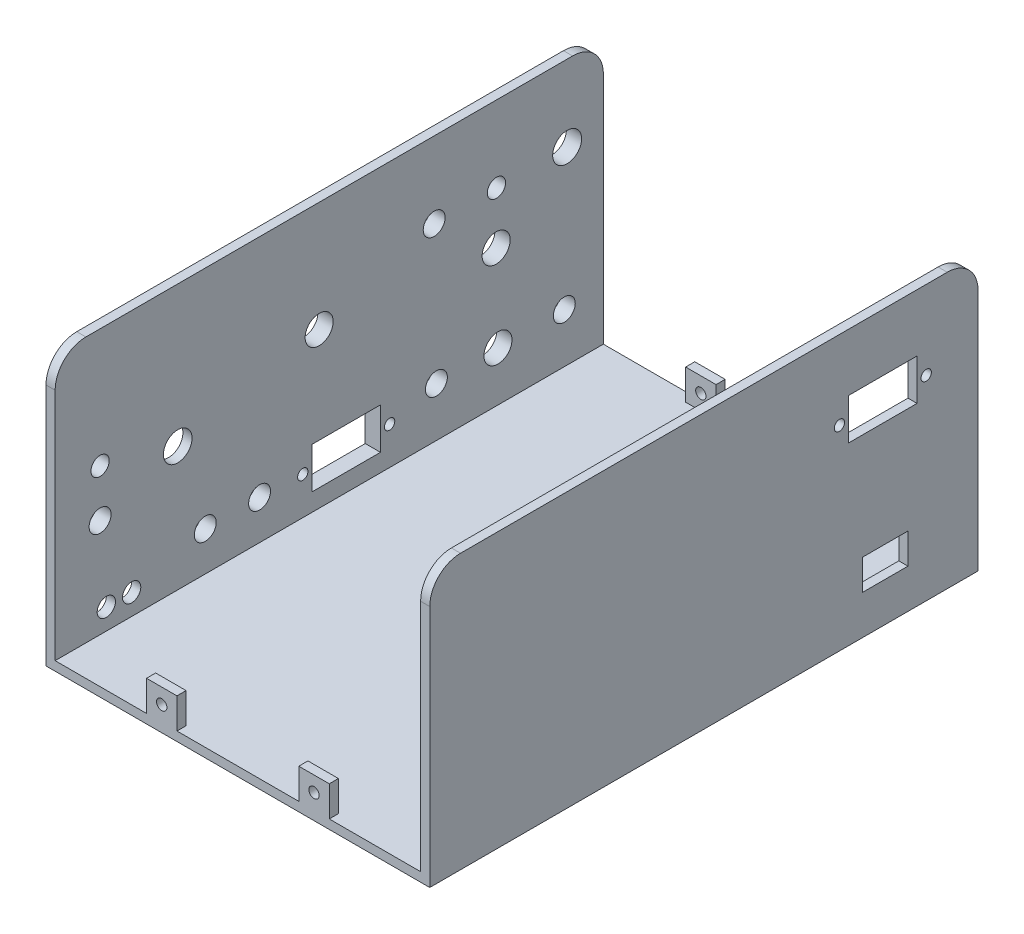
from build123d import *

# Parameters (mm, degrees)
SKETCH1_W           = 126
SKETCH1_H           = 90
BOSS_EXTRUDE1_DEPTH = 3
BOSS_EXTRUDE2_DEPTH = 177
SKETCH3_W           = 126
SKETCH3_H           = 90
BOSS_EXTRUDE3_DEPTH = 3
FILLET1_R           = 10
SKETCH5_R           = 3
CUT_EXTRUDE1_DEPTH  = 5
SKETCH6_W           = 22.5
SKETCH6_H           = 13.5
SKETCH6_W_2         = 15
SKETCH6_H_2         = 10
CUT_EXTRUDE2_DEPTH  = 3
SKETCH7_W           = 180
SKETCH7_H           = 180
BOSS_EXTRUDE5_DEPTH = 3
SKETCH8_OUTSIDE_W   = 236
SKETCH8_OUTSIDE_H   = 146
CUT_EXTRUDE3_DEPTH  = 181
SKETCH9_W           = 120
SKETCH9_H           = 87
CUT_EXTRUDE4_DEPTH  = 181
SKETCH11_W          = 10
SKETCH11_H          = 3
BOSS_EXTRUDE6_DEPTH = 10
SKETCH12_R          = 1.7
CUT_EXTRUDE5_DEPTH  = 10
SKETCH13_R          = 1.7
CUT_EXTRUDE6_DEPTH  = 10
SKETCH16_W          = 60
SKETCH16_H          = 45
SKETCH16_W_2        = 55.136481679
SKETCH16_H_2        = 30
SKETCH16_W_3        = 50
SKETCH16_W_4        = 57.73113964
SKETCH16_W_5        = 14.594951033
SKETCH16_W_6        = 24.912721932
SKETCH16_H_3        = 36.48422414
BOSS_EXTRUDE7_DEPTH = 5
SKETCH15_R          = 4.75
SKETCH15_R_2        = 3
SKETCH15_R_3        = 3.6
SKETCH15_R_4        = 4.6
SKETCH15_R_5        = 4.7
SKETCH15_W          = 22.5
SKETCH15_H          = 13.5
CUT_EXTRUDE7_DEPTH  = 7.5
FILLET3_R           = 2.27
SKETCH17_W          = 54
SKETCH17_H          = 180
CUT_EXTRUDE8_DEPTH  = 10
BOSS_EXTRUDE8_DEPTH = 2
SKETCH19_R          = 1.7
CUT_EXTRUDE9_DEPTH  = 12
SKETCH20_R          = 1.7
CUT_EXTRUDE10_DEPTH = 12


with BuildPart() as part:
    # Sketch1 → Boss-Extrude1 (new body)
    with BuildSketch(Plane.XY):
        with Locations((63, -45)):
            Rectangle(SKETCH1_W, SKETCH1_H)
    extrude(amount=BOSS_EXTRUDE1_DEPTH)

    # Sketch2 → Boss-Extrude2 (add)
    with BuildSketch(Plane(origin=(0, 0, 0), x_dir=(-1, 0, 0), z_dir=(0, 0, -1))):
        Polygon((-126, -90), (-126, 0), (0, 0), (0, -90), (-3, -90), (-3, -3), (-123, -3), (-123, -90), align=None)
    extrude(amount=-BOSS_EXTRUDE2_DEPTH)

    # Sketch3 → Boss-Extrude3 (add)
    with BuildSketch(Plane.XY.offset(177)):
        with Locations((63, -45)):
            Rectangle(SKETCH3_W, SKETCH3_H)
    extrude(amount=BOSS_EXTRUDE3_DEPTH)

    # Fillet1
    fillet1_edges = [part.edges().sort_by_distance(p)[0] for p in [
        (63, -3, 3),
        (63, -3, 177),
        (63, 0, 0),
        (63, 0, 180),
    ]]
    fillet(fillet1_edges, radius=FILLET1_R)

    # Sketch5 → Cut-Extrude1 (cut)
    with BuildSketch(Plane.ZY.offset(2)):
        with Locations((154.879918412, -80.109384213)):
            Circle(SKETCH5_R)
        with Locations((163.20022023, -80.109384213)):
            Circle(SKETCH5_R)
    extrude(amount=-CUT_EXTRUDE1_DEPTH, mode=Mode.SUBTRACT)

    # Sketch6 → Cut-Extrude2 (cut)
    with BuildSketch(Plane(origin=(126, 0, 0), x_dir=(0, 0, -1), z_dir=(1, 0, 0))):
        with Locations((-31.25, -25.595398102)):
            Rectangle(SKETCH6_W, SKETCH6_H)
        with Locations((-30.5, -72.125177246)):
            Rectangle(SKETCH6_W_2, SKETCH6_H_2)
    extrude(amount=-CUT_EXTRUDE2_DEPTH, mode=Mode.SUBTRACT)

    # Sketch7 → Boss-Extrude5 (add)
    with BuildSketch(Plane(origin=(0, -90, 0), x_dir=(-1, 0, 0), z_dir=(0, -1, 0))):
        with Locations((-90, -90)):
            Rectangle(SKETCH7_W, SKETCH7_H)
    extrude(amount=-BOSS_EXTRUDE5_DEPTH)

    # Sketch8 outside → Cut-Extrude3 (cut, through all)
    with BuildSketch(Plane.ZY):
        with Locations((90, -45)):
            Rectangle(SKETCH8_OUTSIDE_W, SKETCH8_OUTSIDE_H)
        with BuildLine():
            Line((0, -79.898662722), (0, -90))
            Line((0, -90), (10.101337278, -90))
            Line((10.101337278, -90), (169.898662722, -90))
            Line((169.898662722, -90), (180, -90))
            Line((180, -90), (180, -79.898662722))
            Line((180, -79.898662722), (180, -10.101337278))
            ThreePointArc((180, -10.101337278), (177.04138681, -2.95861319), (169.898662722, 0))
            Line((169.898662722, 0), (10.101337278, 0))
            ThreePointArc((10.101337278, 0), (2.95861319, -2.95861319), (0, -10.101337278))
            Line((0, -10.101337278), (0, -79.898662722))
        make_face(mode=Mode.SUBTRACT)
    extrude(amount=-CUT_EXTRUDE3_DEPTH, mode=Mode.SUBTRACT)

    # Sketch9 → Cut-Extrude4 (cut, through all)
    with BuildSketch(Plane(origin=(0, 0, 0), x_dir=(-1, 0, 0), z_dir=(0, 0, -1))):
        with Locations((-63, -43.5)):
            Rectangle(SKETCH9_W, SKETCH9_H)
    extrude(amount=-CUT_EXTRUDE4_DEPTH, mode=Mode.SUBTRACT)

    # Sketch11 → Boss-Extrude6 (add)
    with BuildSketch(Plane(origin=(0, -87, 0), x_dir=(1, 0, 0), z_dir=(0, 1, 0))):
        with Locations((38, -178.5)):
            Rectangle(SKETCH11_W, SKETCH11_H)
        with Locations((88, -178.5)):
            Rectangle(SKETCH11_W, SKETCH11_H)
        with Locations((38, -1.5)):
            Rectangle(SKETCH11_W, SKETCH11_H)
        with Locations((88, -1.5)):
            Rectangle(SKETCH11_W, SKETCH11_H)
    extrude(amount=BOSS_EXTRUDE6_DEPTH)

    # Sketch12 → Cut-Extrude5 (cut)
    with BuildSketch(Plane(origin=(0, 0, 0), x_dir=(-1, 0, 0), z_dir=(0, 0, -1))):
        with Locations((-88, -82)):
            Circle(SKETCH12_R)
        with Locations((-38, -82)):
            Circle(SKETCH12_R)
    extrude(amount=-CUT_EXTRUDE5_DEPTH, mode=Mode.SUBTRACT)

    # Sketch13 → Cut-Extrude6 (cut)
    with BuildSketch(Plane.XY.offset(180)):
        with Locations((38, -82)):
            Circle(SKETCH13_R)
        with Locations((88, -82)):
            Circle(SKETCH13_R)
    extrude(amount=-CUT_EXTRUDE6_DEPTH, mode=Mode.SUBTRACT)

    # Sketch16 → Boss-Extrude7 (add)
    with BuildSketch(Plane.ZY.offset(2)):
        with Locations((33.397799687, -29.5)):
            Rectangle(SKETCH16_W, SKETCH16_H)
        with Locations((33.81824084, -70)):
            Rectangle(SKETCH16_W_2, SKETCH16_H_2)
        with Locations((93.535533906, -30.5)):
            Rectangle(SKETCH16_W_3, SKETCH16_H)
        with Locations((92.012227586, -70)):
            Rectangle(SKETCH16_W_4, SKETCH16_H_2)
        with Locations((130.607764761, -69.962221636)):
            Rectangle(SKETCH16_W_5, SKETCH16_H_2)
        with Locations((165.153259598, -44.347490411)):
            Rectangle(SKETCH16_W_6, SKETCH16_H_3)
    extrude(amount=-BOSS_EXTRUDE7_DEPTH)

    # Sketch15 → Cut-Extrude7 (cut, symmetric)
    with BuildSketch(Plane.ZY.offset(2)):
        with Locations((11.897799687, -25)):
            Circle(SKETCH15_R)
        with Locations((35.120412136, -25)):
            Circle(SKETCH15_R_2)
        with Locations((55.547244011, -25)):
            Circle(SKETCH15_R_3)
        with Locations((93.316630751, -36.188493445)):
            Circle(SKETCH15_R_4)
        with Locations((12.826376296, -70.752206375)):
            Circle(SKETCH15_R_3)
        with Locations((54.826376296, -70.752206375)):
            Circle(SKETCH15_R_3)
        with Locations((34.603168291, -70.752206375)):
            Circle(SKETCH15_R_4)
        with Locations((35.201614473, -42.050293137)):
            Circle(SKETCH15_R_4)
        with Locations((112.872652377, -74.126778902)):
            Circle(SKETCH15_R_3)
        with Locations((130.71133323, -74.126778902)):
            Circle(SKETCH15_R_3)
        with Locations((139.753590628, -46.167682179)):
            Circle(SKETCH15_R_5)
        with Locations((165.243179484, -54.550293137)):
            Circle(SKETCH15_R_3)
        with Locations((165.243179484, -38.990832132)):
            Circle(SKETCH15_R_2)
        with Locations((84.43777437, -74.416080578)):
            Rectangle(SKETCH15_W, SKETCH15_H)
    extrude(amount=CUT_EXTRUDE7_DEPTH, both=True, mode=Mode.SUBTRACT)

    # Fillet3
    fillet3_edges = [part.edges().sort_by_distance(p)[0] for p in [
        (-1, -52, 3.397799687),
        (-1, -7, 3.397799687),
        (-1, -7, 63.397799687),
        (-1, -52, 63.397799687),
        (-1, -85, 6.25),
        (-1, -55, 6.25),
        (-1, -55, 61.386481679),
        (-1, -85, 61.386481679),
        (-1, -53, 68.535533906),
        (-1, -8, 68.535533906),
        (-1, -8, 118.535533906),
        (-1, -53, 118.535533906),
        (-1, -85, 63.146657766),
        (-1, -55, 63.146657766),
        (-1, -55, 120.877797406),
        (-1, -85, 120.877797406),
        (-1, -84.962221636, 123.310289245),
        (-1, -54.962221636, 123.310289245),
        (-1, -54.962221636, 137.905240278),
        (-1, -84.962221636, 137.905240278),
        (-1, -62.589602481, 152.696898632),
        (-1, -26.105378341, 152.696898632),
        (-1, -26.105378341, 177.609620564),
        (-1, -62.589602481, 177.609620564),
    ]]
    fillet(fillet3_edges, radius=FILLET3_R)

    # Sketch17 → Cut-Extrude8 (cut)
    with BuildSketch(Plane(origin=(0, -87, 0), x_dir=(1, 0, 0), z_dir=(0, 1, 0))):
        with Locations((153, -90)):
            Rectangle(SKETCH17_W, SKETCH17_H)
    extrude(amount=-CUT_EXTRUDE8_DEPTH, mode=Mode.SUBTRACT)

    # Sketch18 → Boss-Extrude8 (add)
    with BuildSketch(Plane.ZY):
        with BuildLine():
            Line((129, -5), (171, -5))
            ThreePointArc((171, -5), (173.828427125, -6.171572875), (175, -9))
            Line((175, -9), (175, -19))
            ThreePointArc((175, -19), (173.828427125, -21.828427125), (171, -23))
            Line((171, -23), (129, -23))
            ThreePointArc((129, -23), (126.171572875, -21.828427125), (125, -19))
            Line((125, -19), (125, -9))
            ThreePointArc((125, -9), (126.171572875, -6.171572875), (129, -5))
        make_face()
    extrude(amount=BOSS_EXTRUDE8_DEPTH)

    # Sketch19 → Cut-Extrude9 (cut)
    with BuildSketch(Plane.ZY.offset(2)):
        with Locations((98.68777437, -74.666080578)):
            Circle(SKETCH19_R)
        with Locations((70.18777437, -74.666080578)):
            Circle(SKETCH19_R)
    extrude(amount=-CUT_EXTRUDE9_DEPTH, mode=Mode.SUBTRACT)

    # Sketch20 → Cut-Extrude10 (cut)
    with BuildSketch(Plane(origin=(126, 0, 0), x_dir=(0, 0, -1), z_dir=(1, 0, 0))):
        with Locations((-17, -25.845398102)):
            Circle(SKETCH20_R)
        with Locations((-45.5, -25.845398102)):
            Circle(SKETCH20_R)
    extrude(amount=-CUT_EXTRUDE10_DEPTH, mode=Mode.SUBTRACT)


solid = part.part
